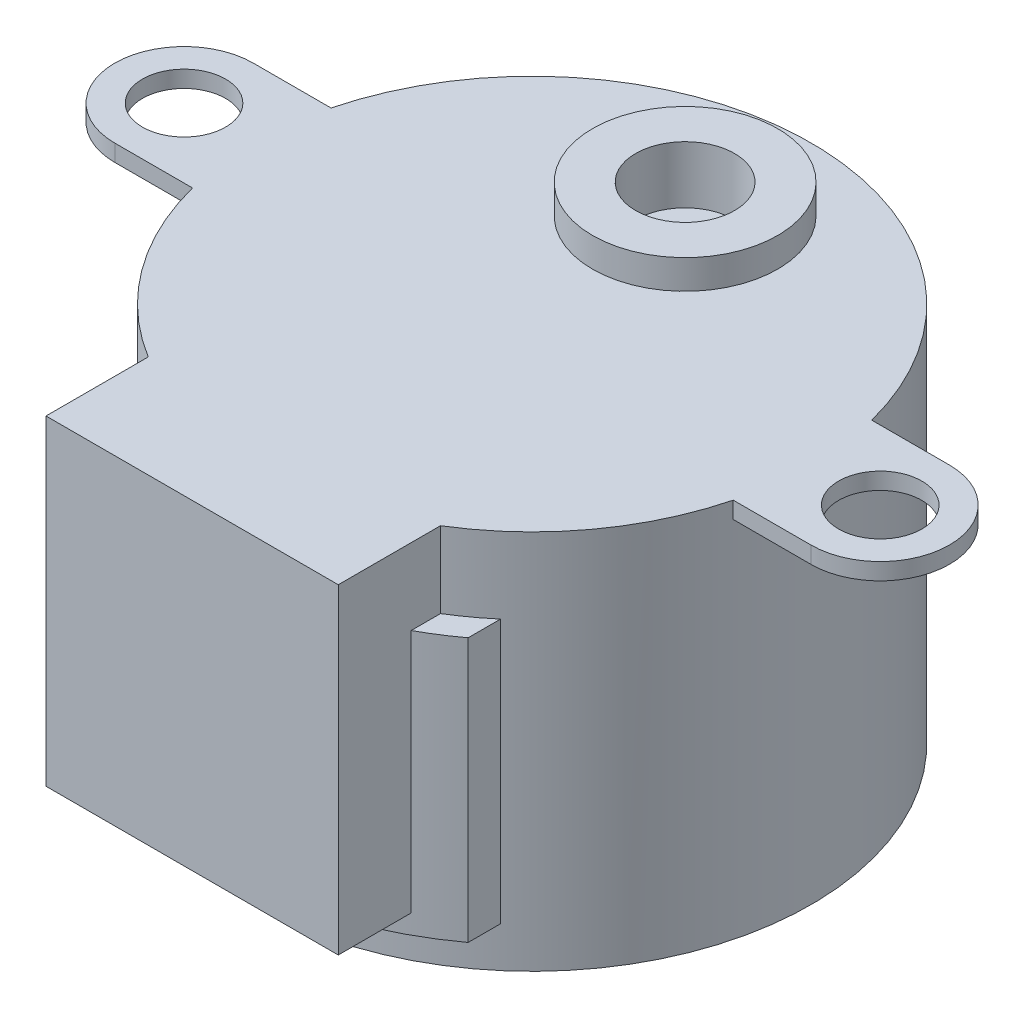
from build123d import *

# Parameters (mm, degrees)
SKETCH1_R           = 13.97
BOSS_EXTRUDE1_DEPTH = 19.05
SKETCH2_R           = 4.6355
BOSS_EXTRUDE2_DEPTH = 1.4605
SKETCH3_R           = 2.4765
BOSS_EXTRUDE3_DEPTH = 7.8232
CUT_EXTRUDE1_DEPTH  = 6.2611
SKETCH6_R           = 13.97
SKETCH6_R_2         = 2.0828
BOSS_EXTRUDE4_DEPTH = 0.8382
BOSS_EXTRUDE5_DEPTH = 16.0528
BOSS_EXTRUDE6_DEPTH = 13.208
SKETCH9_R           = 2.4765
CUT_EXTRUDE2_DEPTH  = 10.6934


with BuildPart() as part:
    # Sketch1 → Boss-Extrude1 (new body)
    with BuildSketch(Plane(origin=(0, 0, 0), x_dir=(1, 0, 0), z_dir=(0, 1, 0))):
        Circle(SKETCH1_R)
    extrude(amount=BOSS_EXTRUDE1_DEPTH)

    # Sketch2 → Boss-Extrude2 (add)
    with BuildSketch(Plane(origin=(0, 19.05, 0), x_dir=(1, 0, 0), z_dir=(0, 1, 0))):
        with Locations((0, 7.6581)):
            Circle(SKETCH2_R)
    extrude(amount=BOSS_EXTRUDE2_DEPTH)

    # Sketch3 → Boss-Extrude3 (add)
    with BuildSketch(Plane(origin=(0, 20.5105, 0), x_dir=(1, 0, 0), z_dir=(0, 1, 0))):
        with Locations((0, 7.6581)):
            Circle(SKETCH3_R)
    extrude(amount=BOSS_EXTRUDE3_DEPTH)

    # Sketch5 → Cut-Extrude1 (cut)
    with BuildSketch(Plane(origin=(0, 28.3337, 0), x_dir=(1, 0, 0), z_dir=(0, 1, 0))):
        with BuildLine():
            ThreePointArc((1.999998, 9.1186), (0, 10.1346), (-1.999998, 9.1186))
            Line((-1.999998, 9.1186), (1.999998, 9.1186))
        make_face()
        with BuildLine():
            Line((1.999998, 6.1976), (-1.999998, 6.1976))
            ThreePointArc((-1.999998, 6.1976), (0, 5.1816), (1.999998, 6.1976))
        make_face()
    extrude(amount=-CUT_EXTRUDE1_DEPTH, mode=Mode.SUBTRACT)

    # Sketch6 → Boss-Extrude4 (add)
    with BuildSketch(Plane(origin=(0, 19.05, 0), x_dir=(1, 0, 0), z_dir=(0, 1, 0))):
        Circle(SKETCH6_R)
        with BuildLine():
            Line((-17.4244, 3.4671), (-13.532927163, 3.4671))
            ThreePointArc((-13.532927163, 3.4671), (-13.97, 0), (-13.532927163, -3.4671))
            Line((-13.532927163, -3.4671), (-17.4244, -3.4671))
            ThreePointArc((-17.4244, -3.4671), (-20.8915, 0), (-17.4244, 3.4671))
        make_face()
        with Locations((-17.4244, 0)):
            Circle(SKETCH6_R_2, mode=Mode.SUBTRACT)
        with BuildLine():
            Line((17.4244, 3.4671), (13.532927163, 3.4671))
            ThreePointArc((13.532927163, 3.4671), (13.97, 0), (13.532927163, -3.4671))
            Line((13.532927163, -3.4671), (17.4244, -3.4671))
            ThreePointArc((17.4244, -3.4671), (20.8915, 0), (17.4244, 3.4671))
        make_face()
        with Locations((17.4244, 0)):
            Circle(SKETCH6_R_2, mode=Mode.SUBTRACT)
    extrude(amount=-BOSS_EXTRUDE4_DEPTH)

    # Sketch7 → Boss-Extrude5 (add)
    with BuildSketch(Plane(origin=(0, 19.05, 0), x_dir=(1, 0, 0), z_dir=(0, 1, 0))):
        with BuildLine():
            Line((7.3152, -17.018), (-7.3152, -17.018))
            Line((-7.3152, -17.018), (-7.3152, -11.901627996))
            ThreePointArc((-7.3152, -11.901627996), (0, -13.97), (7.3152, -11.901627996))
            Line((7.3152, -11.901627996), (7.3152, -17.018))
        make_face()
    extrude(amount=-BOSS_EXTRUDE5_DEPTH)

    # Sketch8 → Boss-Extrude6 (add)
    with BuildSketch(Plane(origin=(0, 15.24, 0), x_dir=(1, 0, 0), z_dir=(0, 1, 0))):
        with BuildLine():
            Line((-9.0551, -10.637953938), (-9.0551, -12.258171315))
            ThreePointArc((-9.0551, -12.258171315), (0, -15.24), (9.0551, -12.258171315))
            Line((9.0551, -12.258171315), (9.0551, -10.637953938))
            ThreePointArc((9.0551, -10.637953938), (0, -13.97), (-9.0551, -10.637953938))
        make_face()
    extrude(amount=-BOSS_EXTRUDE6_DEPTH)

    # Sketch9 → Cut-Extrude2 (cut)
    with BuildSketch(Plane(origin=(0, 28.3337, 0), x_dir=(1, 0, 0), z_dir=(0, 1, 0))):
        with Locations((0, 7.6581)):
            Circle(SKETCH9_R)
    extrude(amount=-CUT_EXTRUDE2_DEPTH, mode=Mode.SUBTRACT)


solid = part.part
